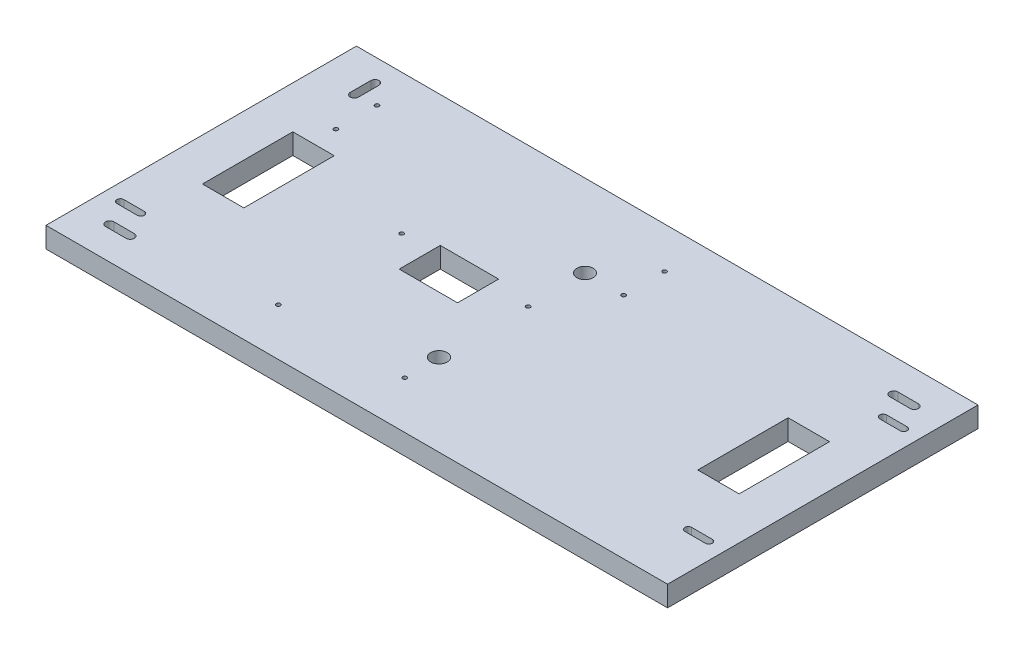
from build123d import *

# Parameters (mm, degrees)
SKETCH1_W           = 192.0875
SKETCH1_H           = 95.9358
BOSS_EXTRUDE1_DEPTH = 6.35
SKETCH8_R           = 0.635
CUT_EXTRUDE2_DEPTH  = 20.05
SKETCH3_R           = 2.54
SKETCH3_W           = 12.8016
SKETCH3_H           = 27.94
SKETCH3_W_2         = 18.034
SKETCH3_H_2         = 12.7
CUT_EXTRUDE3_DEPTH  = 7.35


with BuildPart() as part:
    # Sketch1 → Boss-Extrude1 (new body)
    with BuildSketch(Plane(origin=(0, 0, 0), x_dir=(1, 0, 0), z_dir=(0, 1, 0))):
        with Locations((96.04375, 47.9679)):
            Rectangle(SKETCH1_W, SKETCH1_H)
    extrude(amount=BOSS_EXTRUDE1_DEPTH)

    # Sketch8 → Cut-Extrude2 (cut, through all)
    with BuildSketch(Plane.XZ.offset(12.7)):
        with Locations((19.05, 5.6642)):
            Circle(SKETCH8_R)
        with Locations((19.05, 18.3642)):
            Circle(SKETCH8_R)
        with Locations((19.05, -70.5358)):
            Circle(SKETCH8_R)
        with Locations((19.05, -83.2358)):
            Circle(SKETCH8_R)
        with Locations((57.15, -52.7558)):
            Circle(SKETCH8_R)
        with Locations((57.15, -14.6558)):
            Circle(SKETCH8_R)
        with Locations((96.2406, -14.6558)):
            Circle(SKETCH8_R)
        with Locations((96.2406, -52.7558)):
            Circle(SKETCH8_R)
        with Locations((107.95, -83.2358)):
            Circle(SKETCH8_R)
        with Locations((107.95, -70.5358)):
            Circle(SKETCH8_R)
        with Locations((107.95, 5.6642)):
            Circle(SKETCH8_R)
        with Locations((107.95, 18.3642)):
            Circle(SKETCH8_R)
    extrude(amount=-CUT_EXTRUDE2_DEPTH, mode=Mode.SUBTRACT)

    # Sketch3 → Cut-Extrude3 (cut, through all)
    with BuildSketch(Plane(origin=(0, 0, 0), x_dir=(-1, 0, 0), z_dir=(0, -1, 0))):
        with Locations((-96.04375, 25.4)):
            Circle(SKETCH3_R)
        with Locations((-96.04375, 70.5358)):
            Circle(SKETCH3_R)
        with BuildLine():
            Line((-11.43, 88.9508), (-11.43, 82.6008))
            ThreePointArc((-11.43, 82.6008), (-12.7, 81.3308), (-13.97, 82.6008))
            Line((-13.97, 82.6008), (-13.97, 88.9508))
            ThreePointArc((-13.97, 88.9508), (-12.7, 90.2208), (-11.43, 88.9508))
        make_face()
        with BuildLine():
            Line((-182.5625, 84.5058), (-176.2125, 84.5058))
            ThreePointArc((-176.2125, 84.5058), (-174.9425, 85.7758), (-176.2125, 87.0458))
            Line((-176.2125, 87.0458), (-182.5625, 87.0458))
            ThreePointArc((-182.5625, 87.0458), (-183.8325, 85.7758), (-182.5625, 84.5058))
        make_face()
        with BuildLine():
            Line((-9.525, 11.43), (-15.875, 11.43))
            ThreePointArc((-15.875, 11.43), (-17.145, 10.16), (-15.875, 8.89))
            Line((-15.875, 8.89), (-9.525, 8.89))
            ThreePointArc((-9.525, 8.89), (-8.255, 10.16), (-9.525, 11.43))
        make_face()
        with BuildLine():
            Line((-5.1054, 16.7894), (-11.4554, 16.7894))
            ThreePointArc((-11.4554, 16.7894), (-12.5222, 17.8562), (-11.4554, 18.923))
            Line((-11.4554, 18.923), (-5.1054, 18.923))
            ThreePointArc((-5.1054, 18.923), (-4.0386, 17.8562), (-5.1054, 16.7894))
        make_face()
        with BuildLine():
            Line((-186.9821, 16.7894), (-180.6321, 16.7894))
            ThreePointArc((-180.6321, 16.7894), (-179.5653, 17.8562), (-180.6321, 18.923))
            Line((-180.6321, 18.923), (-186.9821, 18.923))
            ThreePointArc((-186.9821, 18.923), (-188.0489, 17.8562), (-186.9821, 16.7894))
        make_face()
        with Locations((-172.5803, 49.1998)):
            Rectangle(SKETCH3_W, SKETCH3_H)
        with Locations((-19.5072, 49.1998)):
            Rectangle(SKETCH3_W, SKETCH3_H)
        with BuildLine():
            Line((-186.9821, 79.1464), (-180.6321, 79.1464))
            ThreePointArc((-180.6321, 79.1464), (-179.5653, 78.0796), (-180.6321, 77.0128))
            Line((-180.6321, 77.0128), (-186.9821, 77.0128))
            ThreePointArc((-186.9821, 77.0128), (-188.0489, 78.0796), (-186.9821, 79.1464))
        make_face()
        with Locations((-75.311, 49.1998)):
            Rectangle(SKETCH3_W_2, SKETCH3_H_2)
    extrude(amount=-CUT_EXTRUDE3_DEPTH, mode=Mode.SUBTRACT)


solid = part.part
